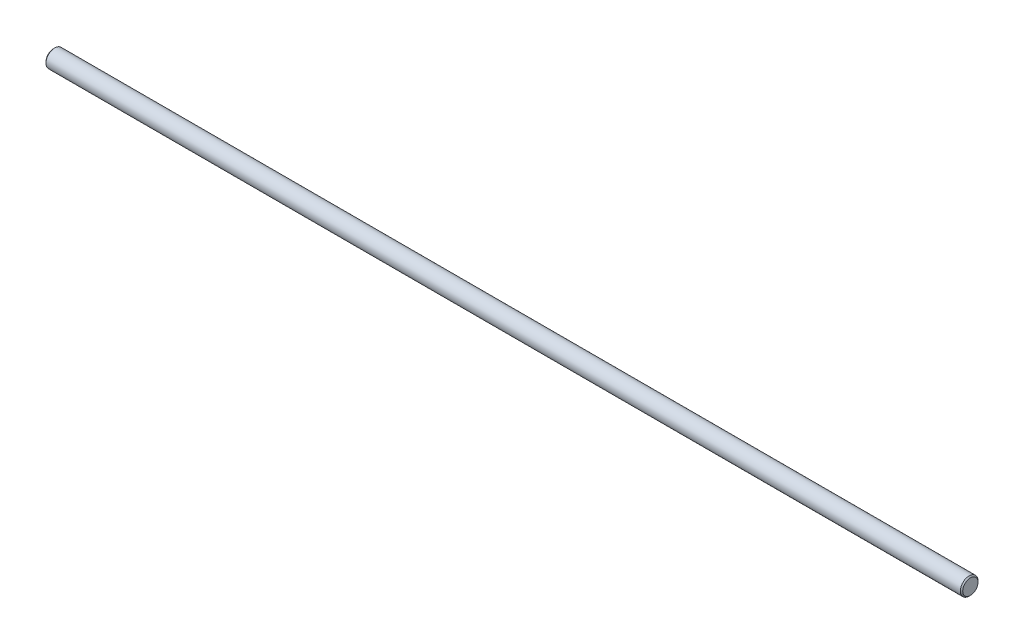
from build123d import *

# Parameters (mm, degrees)
ESQUISSE1_R        = 1.5
BOSS_EXTRU_1_DEPTH = 156
CHANFREIN1_SIZE    = 0.2


with BuildPart() as part:
    # Esquisse1 → Boss.-Extru.1 (new body)
    with BuildSketch(Plane(origin=(0, 0, 0), x_dir=(0, 0, -1), z_dir=(1, 0, 0))):
        Circle(ESQUISSE1_R)
    extrude(amount=BOSS_EXTRU_1_DEPTH)

    # Chanfrein1
    chanfrein1_edges = [part.edges().sort_by_distance(p)[0] for p in [
        (0, 0, 1.5),
        (156, 0, 1.5),
    ]]
    chamfer(chanfrein1_edges, length=CHANFREIN1_SIZE)


solid = part.part
